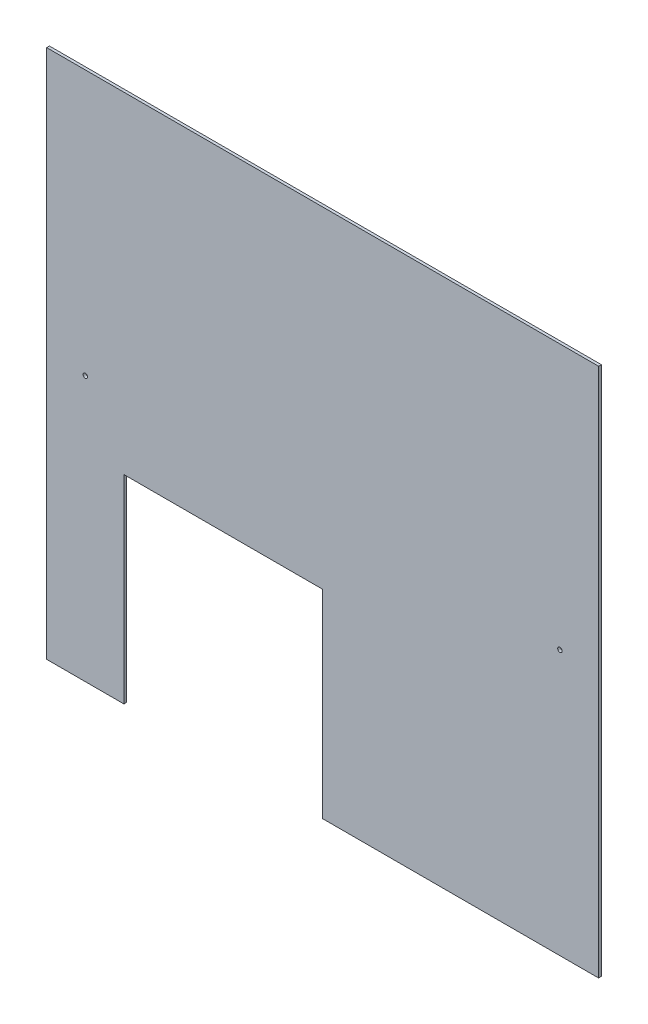
from build123d import *

# Parameters (mm, degrees)
BOSS_EXTRUDE1_DEPTH = 3.175
SKETCH2_R           = 2.5796875
CUT_EXTRUDE1_DEPTH  = 3.175


with BuildPart() as part:
    # Sketch1 → Boss-Extrude1 (new body)
    with BuildSketch(Plane.XY):
        Polygon((-218.243993636, -432.2849642), (-218.243993636, -203.6849642), (10.356006364, -203.6849642), (10.356006364, -432.2849642), (327.856006364, -432.2849642), (327.856006364, 177.3150358), (-307.143993636, 177.3150358), (-307.143993636, -432.2849642), align=None)
    extrude(amount=BOSS_EXTRUDE1_DEPTH)

    # Sketch2 → Cut-Extrude1 (cut)
    with BuildSketch(Plane.XY.offset(3.175)):
        with Locations((-262.693993636, -127.4849642)):
            Circle(SKETCH2_R)
        with Locations((283.406006364, -127.4849642)):
            Circle(SKETCH2_R)
    extrude(amount=-CUT_EXTRUDE1_DEPTH, mode=Mode.SUBTRACT)


solid = part.part
